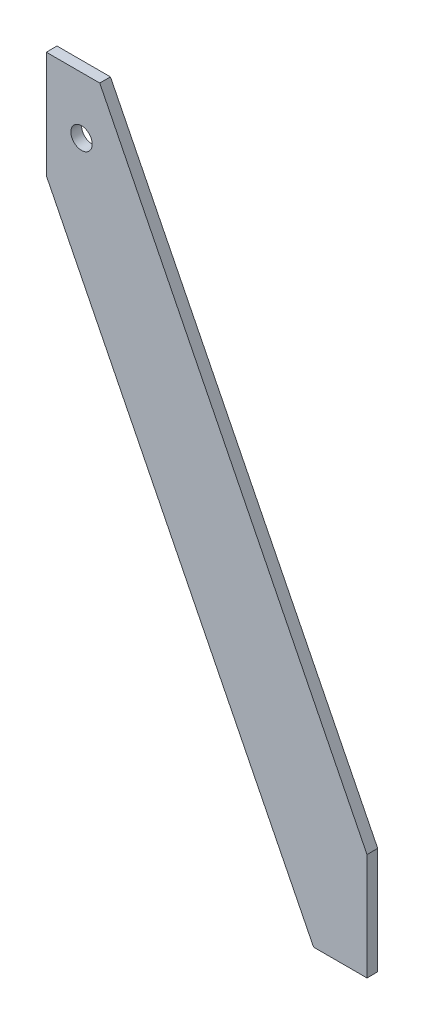
from build123d import *

# Parameters (mm, degrees)
SKETCH1_R           = 4
BOSS_EXTRUDE1_DEPTH = 4


with BuildPart() as part:
    # Sketch1 → Boss-Extrude1 (new body)
    with BuildSketch(Plane.XY):
        Polygon((0, -83.324396783), (0, -43.324396783), (-100, 156.675603217), (-120, 156.675603217), (-120, 116.675603217), (-20, -83.324396783), align=None)
        with Locations((-106.809651475, 135.442359249)):
            Circle(SKETCH1_R, mode=Mode.SUBTRACT)
    extrude(amount=BOSS_EXTRUDE1_DEPTH)


solid = part.part
